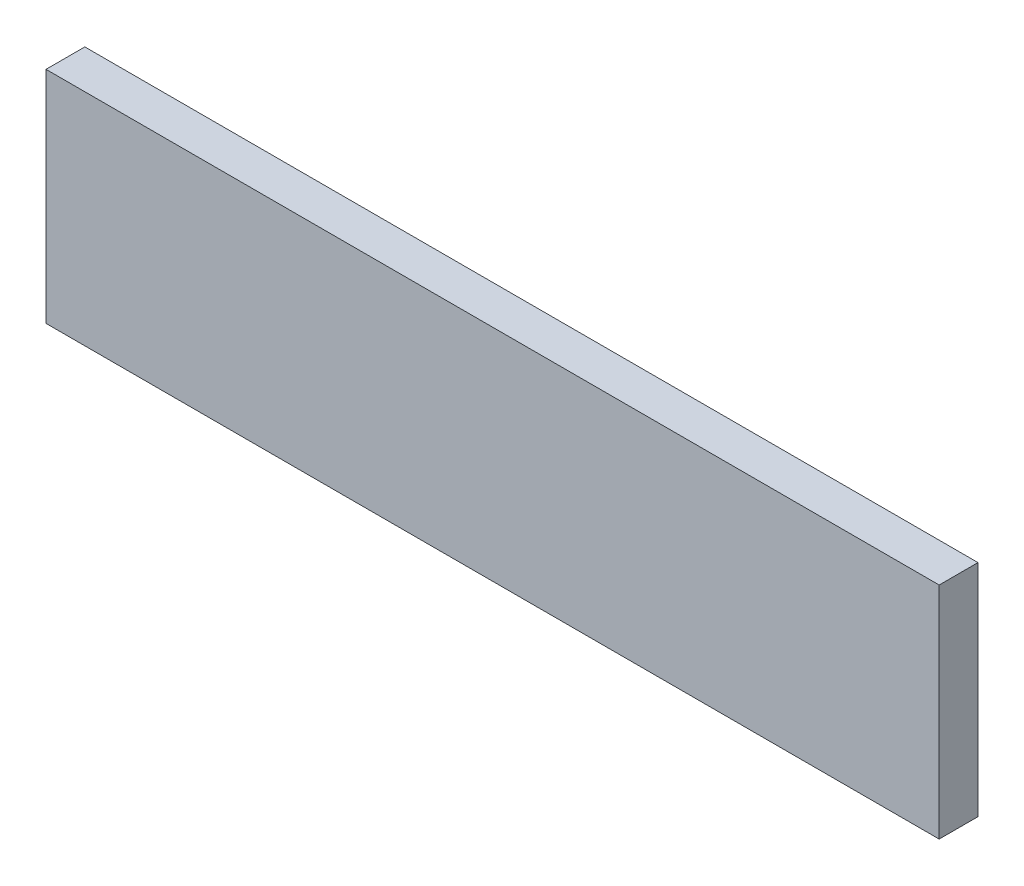
from build123d import *

# Parameters (mm, degrees)
SKETCH1_W           = 438.15
SKETCH1_H           = 107.95
BOSS_EXTRUDE1_DEPTH = 19.05


with BuildPart() as part:
    # Sketch1 → Boss-Extrude1 (new body)
    with BuildSketch(Plane.XY):
        with Locations((219.075, 53.975)):
            Rectangle(SKETCH1_W, SKETCH1_H)
    extrude(amount=BOSS_EXTRUDE1_DEPTH)


solid = part.part
